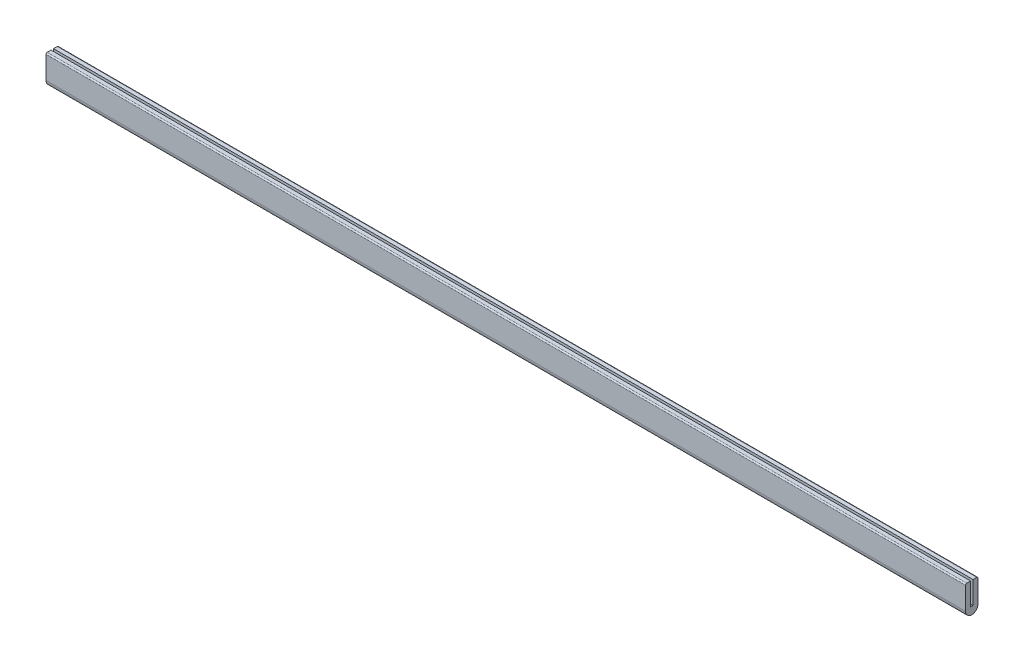
from build123d import *

# Parameters (mm, degrees)
BOSS_EXTRUDE1_DEPTH = 584.2
FILLET1_R           = 1.5875


with BuildPart() as part:
    # Sketch1 → Boss-Extrude1 (new body, symmetric)
    with BuildSketch(Plane(origin=(0, 0, 0), x_dir=(0, 0, -1), z_dir=(1, 0, 0))):
        with BuildLine():
            Line((-1.5875, 28.575), (-7.9375, 28.575))
            Line((-7.9375, 28.575), (-7.9375, -1.5875))
            ThreePointArc((-7.9375, -1.5875), (0, -9.525), (7.9375, -1.5875))
            Line((7.9375, -1.5875), (7.9375, 28.575))
            Line((7.9375, 28.575), (1.5875, 28.575))
            Line((1.5875, 28.575), (1.5875, 0))
            Line((1.5875, 0), (-1.5875, 0))
            Line((-1.5875, 0), (-1.5875, 28.575))
        make_face()
    extrude(amount=BOSS_EXTRUDE1_DEPTH, both=True)

    # Fillet1
    fillet1_edges = [part.edges().sort_by_distance(p)[0] for p in [
        (0, 28.575, -7.9375),
        (0, 28.575, 7.9375),
    ]]
    fillet(fillet1_edges, radius=FILLET1_R)


solid = part.part
